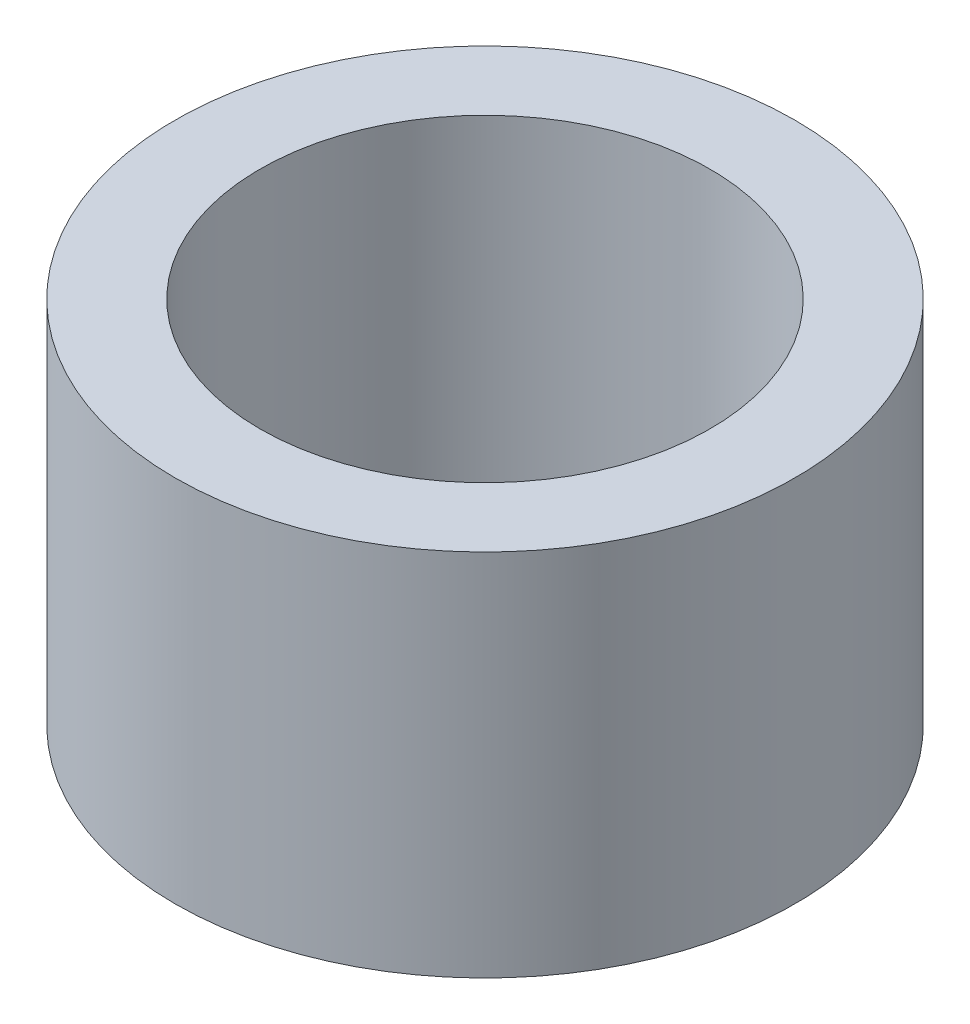
from build123d import *

# Parameters (mm, degrees)
SKETCH_1_R      = 8.4
SKETCH_1_R_2    = 6.1
EXTRUDE_1_DEPTH = 5


with BuildPart() as part:
    # 스케치1 → 보스-돌출1 (new body, symmetric)
    with BuildSketch(Plane(origin=(0, 0, 0), x_dir=(1, 0, 0), z_dir=(0, 1, 0))):
        Circle(SKETCH_1_R)
        Circle(SKETCH_1_R_2, mode=Mode.SUBTRACT)
    extrude(amount=EXTRUDE_1_DEPTH, both=True)


solid = part.part
